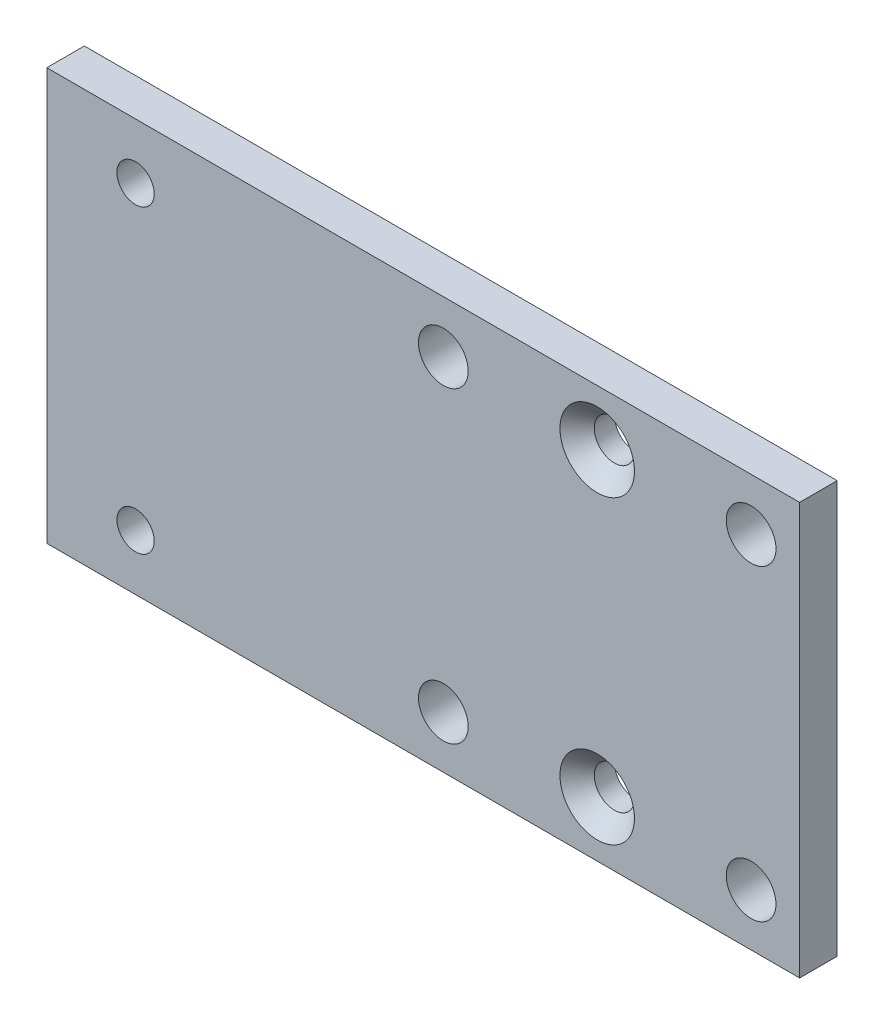
from build123d import *

# Parameters (mm, degrees)
PROFILE_SKETCH_W                                = 63.6
PROFILE_SKETCH_H                                = 34.8
PROFILE_EXTRUDE_DEPTH                           = 3.175
MOUNTING_HOLE_SKETCH_R                          = 1.575
MOUNTING_HOLE_CUT_DEPTH                         = 4.175
CSK_FOR_M3_FLAT_HEAD_MACHINE_SCREW1_D           = 3.4
CSK_FOR_M3_FLAT_HEAD_MACHINE_SCREW1_CSINK_D     = 6.3
CSK_FOR_M3_FLAT_HEAD_MACHINE_SCREW1_CSINK_ANGLE = 90
CARRIAGE_GUIDE_HOLE_SKETCH_R                    = 2.1
CARRIAGE_GUIDE_HOLE_CUT_DEPTH                   = 4.175


with BuildPart() as part:
    # Profile Sketch → Profile Extrude (new body)
    with BuildSketch(Plane.XY):
        Rectangle(PROFILE_SKETCH_W, PROFILE_SKETCH_H)
    extrude(amount=PROFILE_EXTRUDE_DEPTH)

    # Mounting Hole Sketch → Mounting Hole Cut (cut, through all)
    with BuildSketch(Plane.XY.offset(3.175)):
        with Locations((-24.3, 12.7)):
            Circle(MOUNTING_HOLE_SKETCH_R)
        with Locations((-24.3, -12.7)):
            Circle(MOUNTING_HOLE_SKETCH_R)
    extrude(amount=-MOUNTING_HOLE_CUT_DEPTH, mode=Mode.SUBTRACT)

    # CSK for M3 Flat Head Machine Screw1 (through all)
    with Locations(Plane(origin=(14.7, 12.7, 3.175), x_dir=(1, 0, 0), z_dir=(0, 0, 1))):
        with Locations((0, 0), (0, -25.4)):
            CounterSinkHole(CSK_FOR_M3_FLAT_HEAD_MACHINE_SCREW1_D / 2, CSK_FOR_M3_FLAT_HEAD_MACHINE_SCREW1_CSINK_D / 2, counter_sink_angle=CSK_FOR_M3_FLAT_HEAD_MACHINE_SCREW1_CSINK_ANGLE)

    # Carriage Guide Hole Sketch → Carriage Guide Hole Cut (cut, through all)
    with BuildSketch(Plane.XY.offset(3.175)):
        with Locations((1.7, 13)):
            Circle(CARRIAGE_GUIDE_HOLE_SKETCH_R)
        with Locations((27.7, 13)):
            Circle(CARRIAGE_GUIDE_HOLE_SKETCH_R)
        with Locations((27.7, -13)):
            Circle(CARRIAGE_GUIDE_HOLE_SKETCH_R)
        with Locations((1.7, -13)):
            Circle(CARRIAGE_GUIDE_HOLE_SKETCH_R)
    extrude(amount=-CARRIAGE_GUIDE_HOLE_CUT_DEPTH, mode=Mode.SUBTRACT)


solid = part.part
